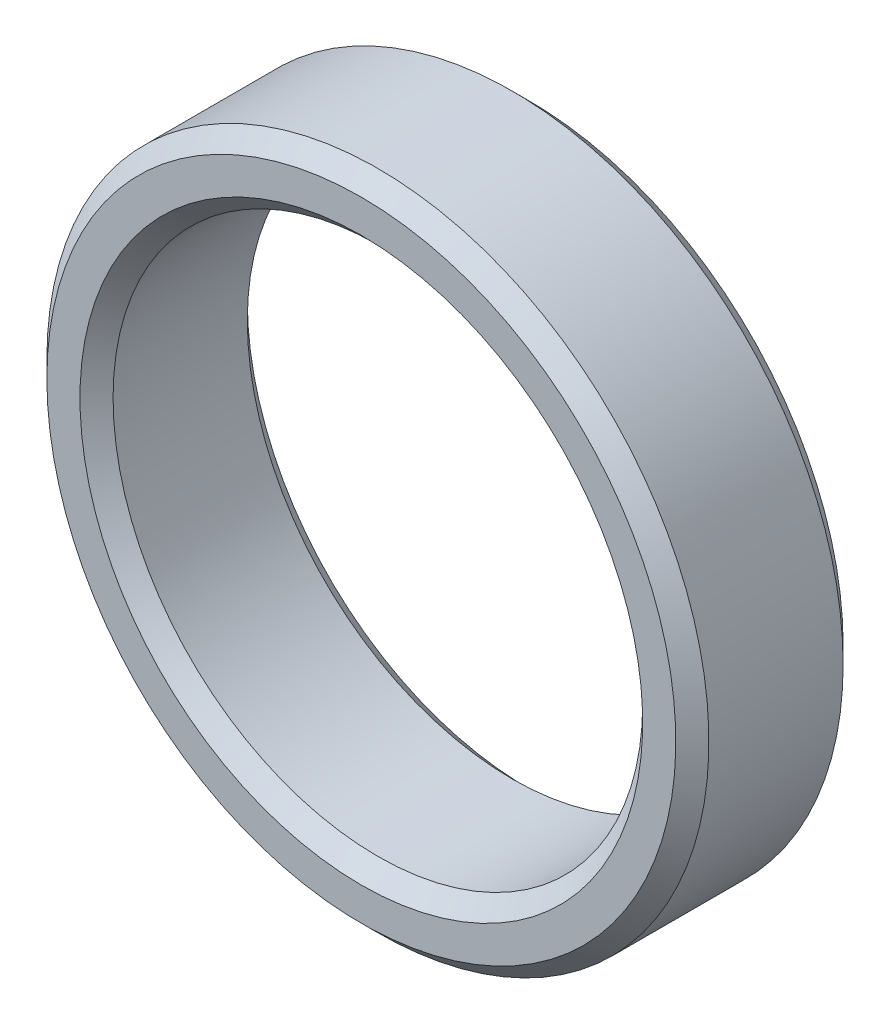
from build123d import *

# Parameters (mm, degrees)
SKETCH1_R           = 15.875
SKETCH1_R_2         = 12.7
BOSS_EXTRUDE1_DEPTH = 8.025
CHAMFER1_SIZE       = 0.79375


with BuildPart() as part:
    # Sketch1 → Boss-Extrude1 (new body)
    with BuildSketch(Plane.XY):
        Circle(SKETCH1_R)
        Circle(SKETCH1_R_2, mode=Mode.SUBTRACT)
    extrude(amount=BOSS_EXTRUDE1_DEPTH)

    # Chamfer1
    chamfer1_edges = [part.edges().sort_by_distance(p)[0] for p in [
        (-15.875, 0, 0),
        (-12.7, 0, 8.025),
        (-12.7, 0, 0),
        (-15.875, 0, 8.025),
    ]]
    chamfer(chamfer1_edges, length=CHAMFER1_SIZE)


solid = part.part
